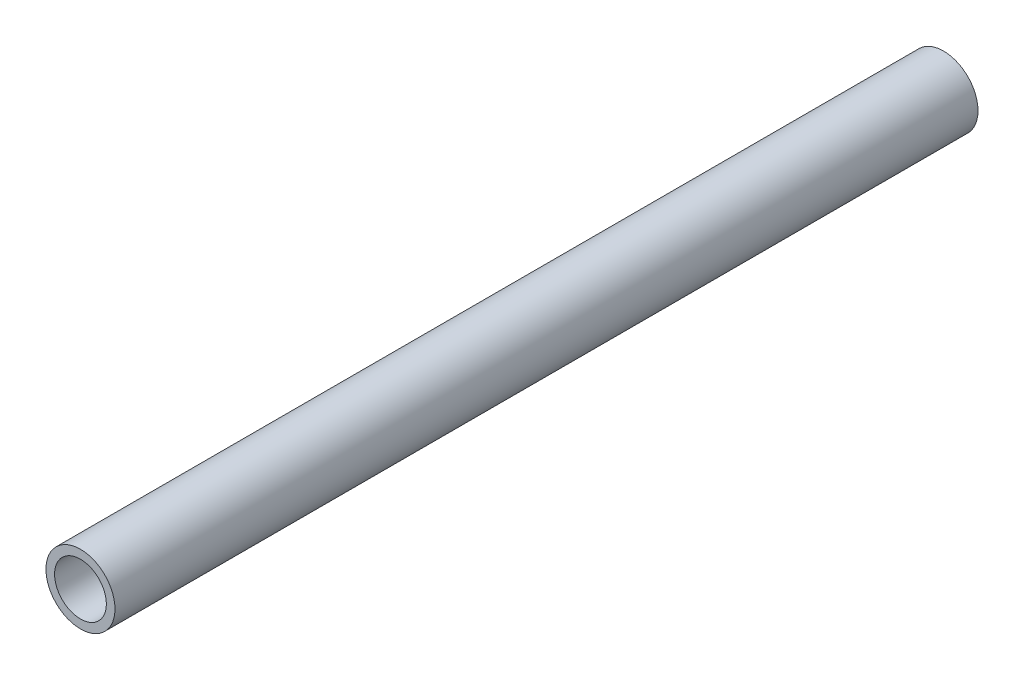
from build123d import *

# Parameters (mm, degrees)
SKETCH1_R           = 4
SKETCH1_R_2         = 3
BOSS_EXTRUDE1_DEPTH = 50


with BuildPart() as part:
    # Sketch1 → Boss-Extrude1 (new body, symmetric)
    with BuildSketch(Plane.XY):
        Circle(SKETCH1_R)
        Circle(SKETCH1_R_2, mode=Mode.SUBTRACT)
    extrude(amount=BOSS_EXTRUDE1_DEPTH, both=True)


solid = part.part
